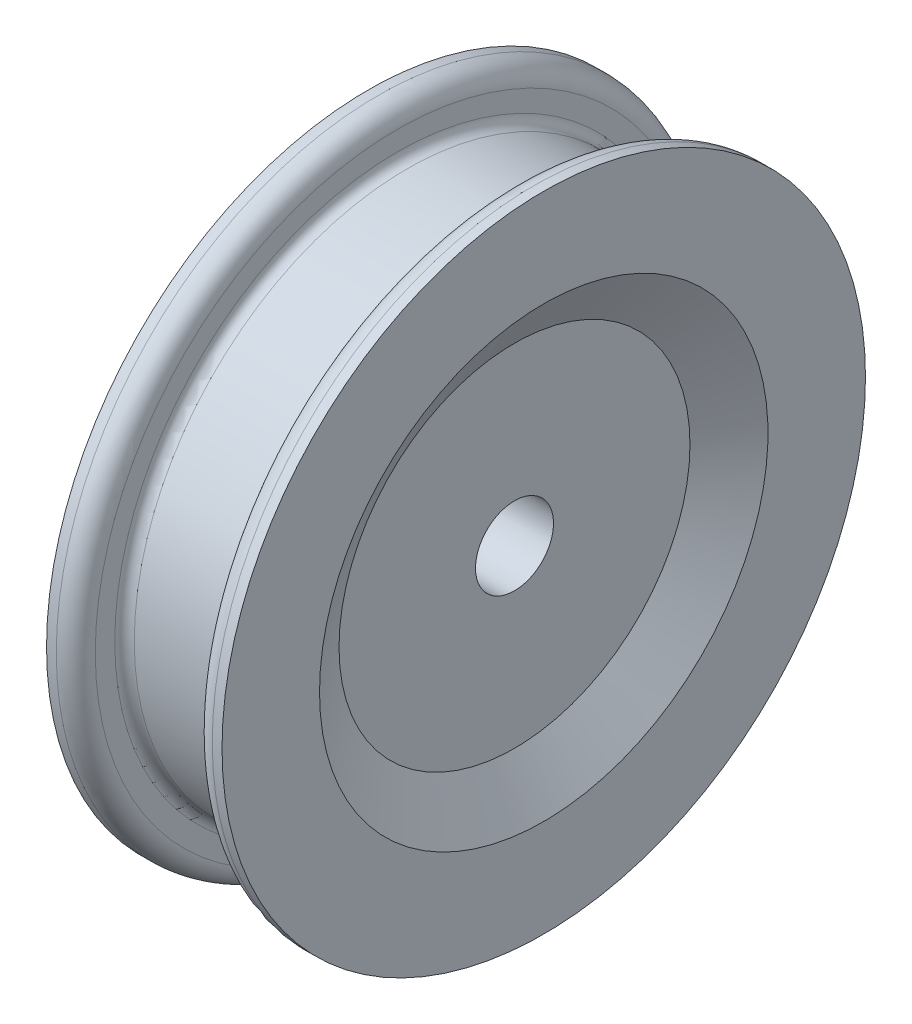
from build123d import *

# Parameters (mm, degrees)
FILLET1_R = 0.5


with BuildPart() as part:
    # Sketch1 → Revolve1 (revolve)
    with BuildSketch(Plane.XY):
        with BuildLine():
            Line((-1.5, 1), (1.5, 1))
            Line((1.5, 1), (1.5, 4.5))
            Line((1.5, 4.5), (2.25, 5.75))
            Line((2.25, 5.75), (2.25, 8.25))
            Line((2.25, 8.25), (1.5, 8.25))
            Line((1.5, 8.25), (1.5, 7.25))
            ThreePointArc((1.5, 7.25), (1.426776695, 7.073223305), (1.25, 7))
            Line((1.25, 7), (-1.25, 7))
            ThreePointArc((-1.25, 7), (-1.426776695, 7.073223305), (-1.5, 7.25))
            Line((-1.5, 7.25), (-1.5, 8.25))
            Line((-1.5, 8.25), (-2.25, 8.25))
            Line((-2.25, 8.25), (-2.25, 5.75))
            Line((-2.25, 5.75), (-1.5, 4.5))
            Line((-1.5, 4.5), (-1.5, 1))
        make_face()
    revolve(axis=Axis((0, 0, 0), (1, 0, 0)))

    # Fillet1
    fillet1_edges = [part.edges().sort_by_distance(p)[0] for p in [
        (-1.5, -8.25, 0),
        (1.5, -8.25, 0),
    ]]
    fillet(fillet1_edges, radius=FILLET1_R)


solid = part.part
